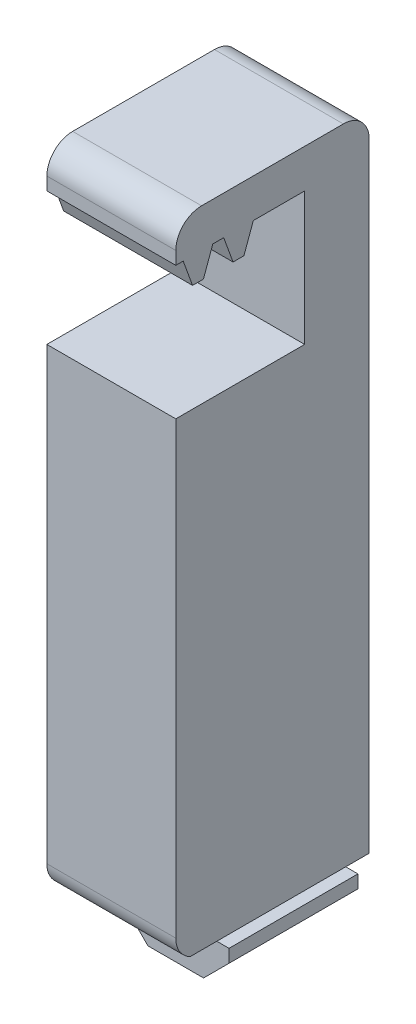
from build123d import *

# Parameters (mm, degrees)
BOSS_EXTRUDE1_DEPTH = 6.35
CUT_EXTRUDE1_DEPTH  = 13.7
CUT_EXTRUDE2_DEPTH  = 20.05
FILLET1_R           = 2.54
CUT_EXTRUDE3_DEPTH  = 20.05
SKETCH6_W           = 12.7
SKETCH6_H           = 0.396875
CUT_EXTRUDE4_DEPTH  = 13.7


with BuildPart() as part:
    # Sketch1 → Boss-Extrude1 (new body, symmetric)
    with BuildSketch(Plane(origin=(0, 0, 0), x_dir=(0, 0, -1), z_dir=(1, 0, 0))):
        Polygon((6.35, 0), (6.35, -6.096), (19.05, -6.096), (19.05, 63.754508), (12.7, 63.754508), (0, 63.754508), (0, 57.404508), (12.7, 57.404508), (12.7, 47.244508), (0, 47.244508), (0, 0), align=None)
    extrude(amount=BOSS_EXTRUDE1_DEPTH, both=True)

    # Sketch2 → Cut-Extrude1 (cut, through all)
    with BuildSketch(Plane(origin=(6.35, 0, 0), x_dir=(0, 0, -1), z_dir=(1, 0, 0))):
        with BuildLine():
            Line((12.7, 57.404508), (6.715252, 57.404508))
            Line((6.715252, 57.404508), (6.665278777, 57.267207698))
            ThreePointArc((6.665278777, 57.267207698), (6.572077823, 57.14574585), (6.426064417, 57.099708))
            Line((6.426064417, 57.099708), (5.934007978, 57.099708))
            ThreePointArc((5.934007978, 57.099708), (5.787994572, 57.14574585), (5.694793618, 57.267207698))
            Line((5.694793618, 57.267207698), (5.644820395, 57.404508))
            Line((5.644820395, 57.404508), (2.72542, 57.404508))
            Line((2.72542, 57.404508), (2.675446777, 57.267207698))
            ThreePointArc((2.675446777, 57.267207698), (2.582245823, 57.14574585), (2.436232417, 57.099708))
            Line((2.436232417, 57.099708), (1.944175978, 57.099708))
            ThreePointArc((1.944175978, 57.099708), (1.798162572, 57.14574585), (1.704961618, 57.267207698))
            Line((1.704961618, 57.267207698), (1.654988395, 57.404508))
            Line((1.654988395, 57.404508), (0, 57.404508))
            Line((0, 57.404508), (0, 47.244508))
            Line((0, 47.244508), (12.7, 47.244508))
            Line((12.7, 47.244508), (12.7, 57.404508))
        make_face()
        Polygon((2.72542, 57.404508), (5.644820395, 57.404508), (4.720336, 59.944508), (3.649904395, 59.944508), align=None)
        Polygon((0, 57.404508), (1.654988395, 57.404508), (0.730504, 59.944508), (0, 59.944508), align=None)
        Polygon((8.710168, 59.944508), (7.639736395, 59.944508), (6.715252, 57.404508), (12.7, 57.404508), (12.7, 59.944508), align=None)
    extrude(amount=-CUT_EXTRUDE1_DEPTH, mode=Mode.SUBTRACT)

    # Sketch3 → Cut-Extrude2 (cut, through all)
    with BuildSketch(Plane(origin=(0, 0, -19.05), x_dir=(-1, 0, 0), z_dir=(0, 0, -1))):
        Polygon((-6.35, -6.096), (-2.839339828, -6.1), (-5.5, -3.439339828), (-5.5, -1.8), (-3.125, -1.8), (-3.125, -1.455), (-4.58, 0), (-9.5, 0), align=None)
        Polygon((2.839339828, -6.1), (6.35, -6.096), (15.42, 0), (4.58, 0), (3.125, -1.455), (3.125, -1.8), (5.5, -1.8), (5.5, -3.439339828), align=None)
    extrude(amount=-CUT_EXTRUDE2_DEPTH, mode=Mode.SUBTRACT)

    # Fillet1
    fillet1_edges = [part.edges().sort_by_distance(p)[0] for p in [
        (0, 63.754508, 0),
        (0, 63.754508, -19.05),
        (0, 0, 0),
    ]]
    fillet(fillet1_edges, radius=FILLET1_R)

    # Sketch5 → Cut-Extrude3 (cut, through all)
    with BuildSketch(Plane(origin=(0, 0, -19.05), x_dir=(-1, 0, 0), z_dir=(0, 0, -1))):
        Polygon((6.35, 0), (4.58, 0), (3.125, -1.455), (3.125, -1.8), (5.5, -1.8), (5.5, -3.439339828), (2.843339828, -6.096), (-2.843339828, -6.096), (-5.5, -3.439339828), (-5.5, -1.8), (-3.125, -1.8), (-3.125, -1.455), (-4.58, 0), (-6.35, 0), (-6.35, 0.254), (-4.474789755, 0.254), (-2.871, -1.349789755), (-2.871, -2.054), (-5.246, -2.054), (-5.246, -3.334129583), (-2.738129583, -5.842), (2.738129583, -5.842), (5.246, -3.334129583), (5.246, -2.054), (2.871, -2.054), (2.871, -1.349789755), (4.474789755, 0.254), (6.35, 0.254), align=None)
    extrude(amount=-CUT_EXTRUDE3_DEPTH, mode=Mode.SUBTRACT)

    # Sketch6 → Cut-Extrude4 (cut, through all)
    with BuildSketch(Plane(origin=(6.35, 0, 0), x_dir=(0, 0, -1), z_dir=(1, 0, 0))):
        with Locations((6.35, 47.0460705)):
            Rectangle(SKETCH6_W, SKETCH6_H)
    extrude(amount=-CUT_EXTRUDE4_DEPTH, mode=Mode.SUBTRACT)


solid = part.part
